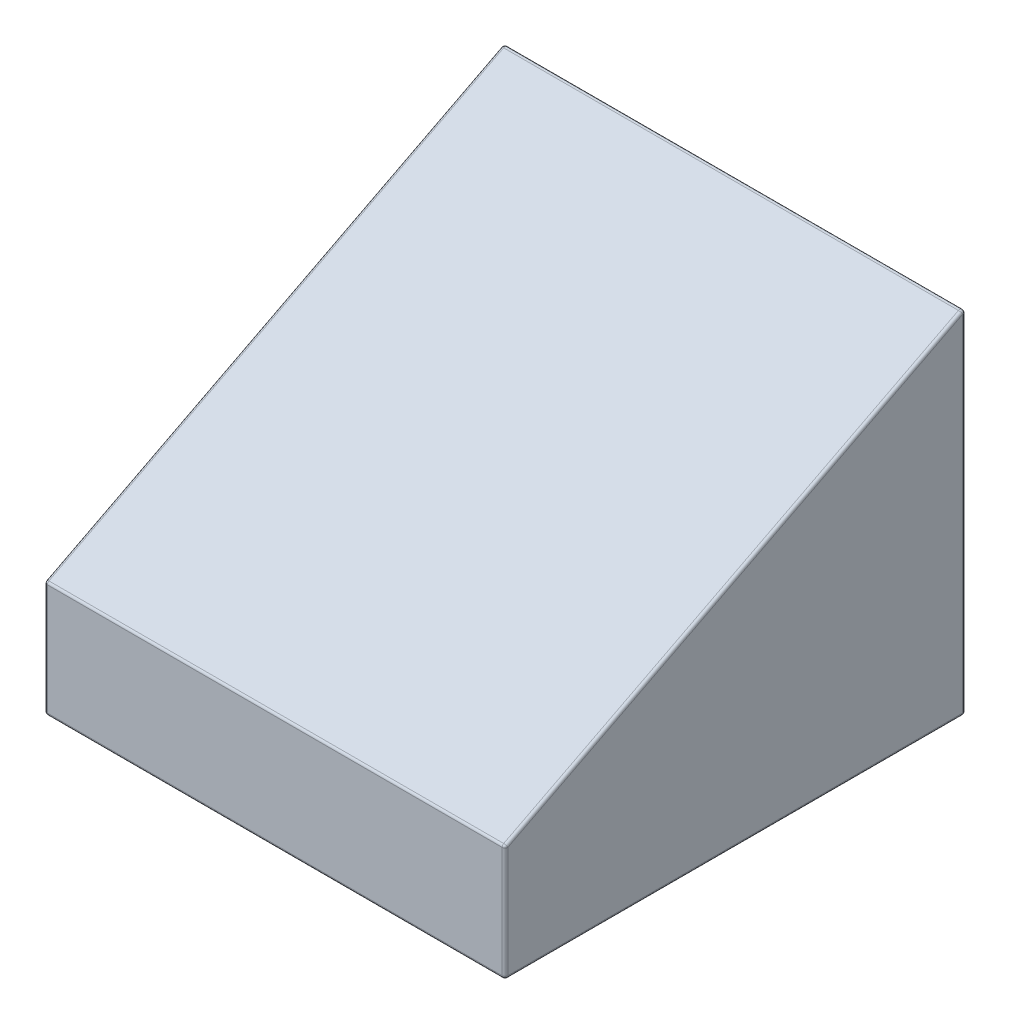
from build123d import *

# Parameters (mm, degrees)
SKETCH1_W      = 7.96
SKETCH1_H      = 7.96
EXTRUDE1_DEPTH = 6.3
EXTRUDE2_DEPTH = 8.96
SHELL1_T       = -1.55
EXTRUDE4_DEPTH = 4.86
SKETCH6_W      = 7.96
SKETCH6_H      = 7.96
SKETCH6_W_2    = 7.56
SKETCH6_H_2    = 7.56
EXTRUDE5_DEPTH = 0.2
FILLET1_R      = 0.05


with BuildPart() as part:
    # Sketch1 → Extrude1 (new body)
    with BuildSketch(Plane(origin=(0, 0, 0), x_dir=(1, 0, 0), z_dir=(0, 1, 0))):
        Rectangle(SKETCH1_W, SKETCH1_H)
    extrude(amount=EXTRUDE1_DEPTH)

    # Sketch2 → Extrude2 (cut, through all)
    with BuildSketch(Plane(origin=(3.98, 0, 0), x_dir=(0, 0, -1), z_dir=(1, 0, 0))):
        Polygon((-3.98, 2.2), (3.98, 6.3), (-3.98, 6.3), align=None)
    extrude(amount=-EXTRUDE2_DEPTH, mode=Mode.SUBTRACT)

    # Shell1
    shell1_openings = [part.faces().sort_by_distance(p)[0] for p in [
        (0, 0, 0),
    ]]
    offset(amount=SHELL1_T, openings=shell1_openings, kind=Kind.INTERSECTION)

    # Sketch5 → Extrude4 (cut)
    with BuildSketch(Plane(origin=(-2.43, 0, 0), x_dir=(0, 0, -1), z_dir=(1, 0, 0))):
        Polygon((-2.43, 0), (2.43, 0), (2.43, 3.915585189), (-2.43, 1.412318857), align=None)
    extrude(amount=EXTRUDE4_DEPTH, mode=Mode.SUBTRACT)

    # Sketch6 → Extrude5 (cut)
    with BuildSketch(Plane.XZ):
        Rectangle(SKETCH6_W, SKETCH6_H)
        Rectangle(SKETCH6_W_2, SKETCH6_H_2, mode=Mode.SUBTRACT)
    extrude(amount=-EXTRUDE5_DEPTH, mode=Mode.SUBTRACT)

    # Fillet1
    fillet1_edges = [part.edges().sort_by_distance(p)[0] for p in [
        (3.98, 1.2, 3.98),
        (-3.98, 1.2, 3.98),
        (0, 2.2, 3.98),
        (-3.98, 4.25, 0),
        (3.98, 4.25, 0),
        (2.43, 0.706159428, 2.43),
        (2.43, 0, 0),
        (0, 0, -2.43),
        (2.43, 1.957792594, -2.43),
        (-2.43, 1.957792594, -2.43),
        (-2.43, 0, 0),
        (-2.43, 0.706159428, 2.43),
        (0, 0, 2.43),
        (2.43, 2.663952023, 0),
        (0, 3.915585189, -2.43),
        (-2.43, 2.663952023, 0),
        (0, 1.412318857, 2.43),
        (-3.98, 0.2, 0),
        (0, 0.2, 3.98),
        (3.98, 0.2, 0),
        (0, 0.2, -3.98),
        (-3.78, 0.2, 0),
        (0, 0.2, -3.78),
        (3.78, 0.2, 0),
        (0, 0.2, 3.78),
        (-3.78, 0, 0),
        (-3.78, 0.1, 3.78),
        (0, 0, 3.78),
        (3.78, 0.1, 3.78),
        (3.78, 0, 0),
        (3.78, 0.1, -3.78),
        (0, 0, -3.78),
        (-3.78, 0.1, -3.78),
        (0, 6.3, -3.98),
        (-3.98, 3.25, -3.98),
        (3.98, 3.25, -3.98),
    ]]
    fillet(fillet1_edges, radius=FILLET1_R)


solid = part.part
